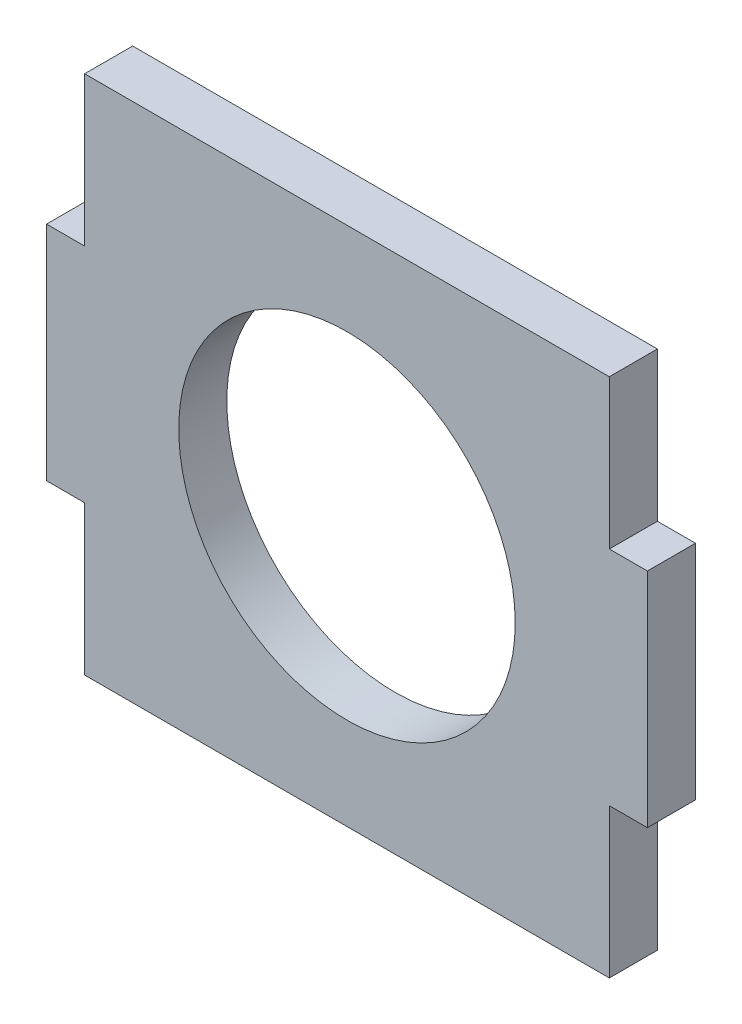
from build123d import *

# Parameters (mm, degrees)
CROQUIS1_W              = 15
CROQUIS1_H              = 13
SALIENTE_EXTRUIR1_DEPTH = 1.2
CORTAR_EXTRUIR1_REACH   = 3.2
CROQUIS2_W              = 0.95
CROQUIS2_H              = 3.725
CORTAR_EXTRUIR2_REACH   = 3.2
CROQUIS3_R              = 4.2


with BuildPart() as part:
    # Croquis1 → Saliente-Extruir1 (new body)
    with BuildSketch(Plane.XY):
        Rectangle(CROQUIS1_W, CROQUIS1_H)
    extrude(amount=SALIENTE_EXTRUIR1_DEPTH)

    # Croquis2 → Cortar-Extruir1 (cut, up to next)
    with BuildSketch(Plane.XY.offset(1.2), mode=Mode.PRIVATE) as cortar_extruir1_sk1:
        with Locations((7.025, 4.6375)):
            Rectangle(CROQUIS2_W, CROQUIS2_H)
    cortar_extruir1_tool1 = extrude(cortar_extruir1_sk1.sketch, amount=-CORTAR_EXTRUIR1_REACH, mode=Mode.PRIVATE) & part.part
    add(cortar_extruir1_tool1.solids().sort_by_distance((7.025, 4.6375, 1.2))[0], mode=Mode.SUBTRACT)
    # Croquis2 → Cortar-Extruir1 (cut, up to next)
    with BuildSketch(Plane.XY.offset(1.2), mode=Mode.PRIVATE) as cortar_extruir1_sk2:
        with Locations((7.025, -4.6375)):
            Rectangle(CROQUIS2_W, CROQUIS2_H)
    cortar_extruir1_tool2 = extrude(cortar_extruir1_sk2.sketch, amount=-CORTAR_EXTRUIR1_REACH, mode=Mode.PRIVATE) & part.part
    add(cortar_extruir1_tool2.solids().sort_by_distance((7.025, -4.6375, 1.2))[0], mode=Mode.SUBTRACT)
    # Croquis2 → Cortar-Extruir1 (cut, up to next)
    with BuildSketch(Plane.XY.offset(1.2), mode=Mode.PRIVATE) as cortar_extruir1_sk3:
        with Locations((-7.025, -4.6375)):
            Rectangle(CROQUIS2_W, CROQUIS2_H)
    cortar_extruir1_tool3 = extrude(cortar_extruir1_sk3.sketch, amount=-CORTAR_EXTRUIR1_REACH, mode=Mode.PRIVATE) & part.part
    add(cortar_extruir1_tool3.solids().sort_by_distance((-7.025, -4.6375, 1.2))[0], mode=Mode.SUBTRACT)
    # Croquis2 → Cortar-Extruir1 (cut, up to next)
    with BuildSketch(Plane.XY.offset(1.2), mode=Mode.PRIVATE) as cortar_extruir1_sk4:
        with Locations((-7.025, 4.6375)):
            Rectangle(CROQUIS2_W, CROQUIS2_H)
    cortar_extruir1_tool4 = extrude(cortar_extruir1_sk4.sketch, amount=-CORTAR_EXTRUIR1_REACH, mode=Mode.PRIVATE) & part.part
    add(cortar_extruir1_tool4.solids().sort_by_distance((-7.025, 4.6375, 1.2))[0], mode=Mode.SUBTRACT)

    # Croquis3 → Cortar-Extruir2 (cut, up to next)
    with BuildSketch(Plane.XY.offset(1.2), mode=Mode.PRIVATE) as cortar_extruir2_sk1:
        Circle(CROQUIS3_R)
    cortar_extruir2_tool1 = extrude(cortar_extruir2_sk1.sketch, amount=-CORTAR_EXTRUIR2_REACH, mode=Mode.PRIVATE) & part.part
    add(cortar_extruir2_tool1.solids().sort_by_distance((0, 0, 1.2))[0], mode=Mode.SUBTRACT)


solid = part.part
